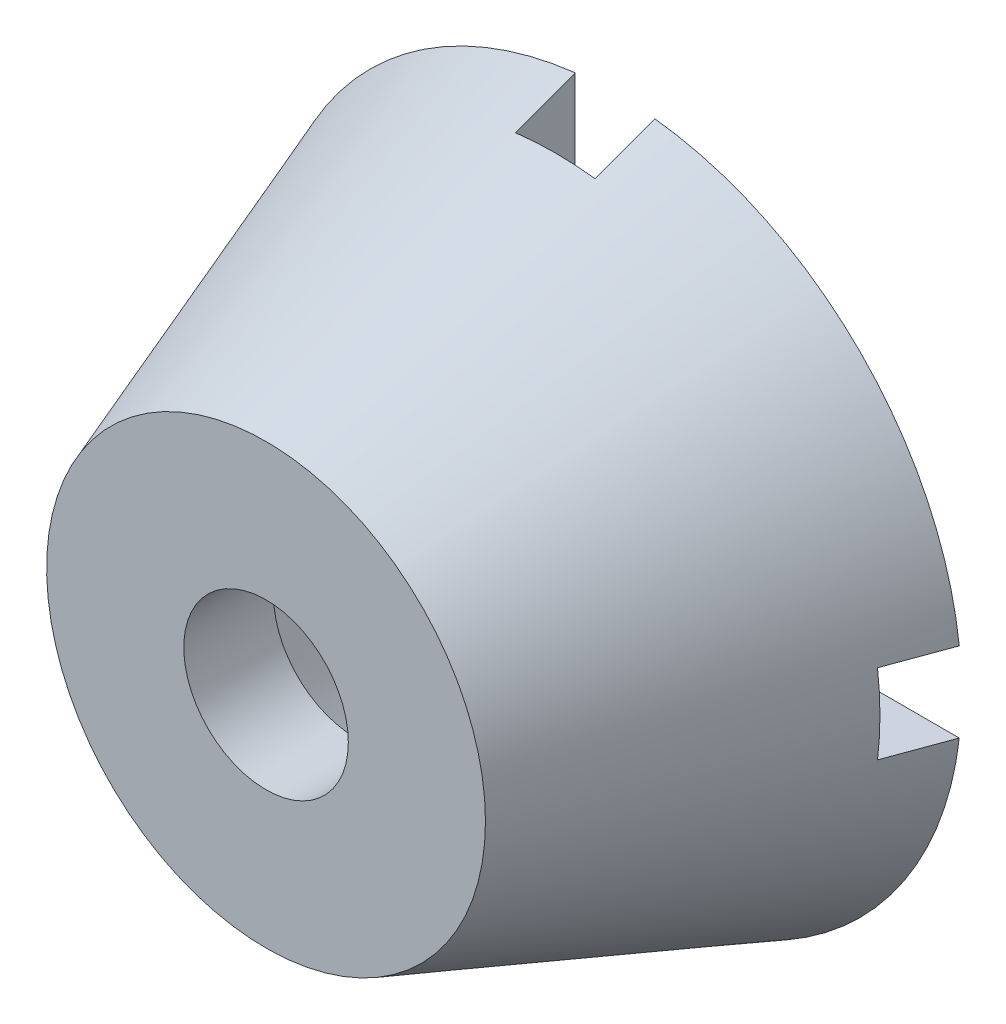
from build123d import *

# Parameters (mm, degrees)
CUT_EXTRUDE_1_REACH      = 37
SKETCH_2_R               = 8.25
SKETCH_3_W               = 8
SKETCH_3_H               = 6
CUT_EXTRUDE_2_DEPTH      = 35.738958199
PATTERN_CIRCULAR_1_COUNT = 4


with BuildPart() as part:
    # 草图1 → 旋转1 (revolve)
    with BuildSketch(Plane(origin=(0, 0, 0), x_dir=(1, 0, 0), z_dir=(0, 1, 0))):
        Polygon((-22, 0), (0, 0), (0, 9), (-15.698132156, 9), (-25.161358247, 35), (-34.738958199, 35), align=None)
    revolve(axis=Axis((0, 0, 0), (0, 0, -1)))

    # 草图2 → 切除-拉伸1 (cut, up to next)
    with BuildSketch(Plane.XY, mode=Mode.PRIVATE) as cut_extrude_1_sk1:
        Circle(SKETCH_2_R)
    cut_extrude_1_tool1 = extrude(cut_extrude_1_sk1.sketch, amount=-CUT_EXTRUDE_1_REACH, mode=Mode.PRIVATE) & part.part
    add(cut_extrude_1_tool1.solids().sort_by_distance((0, 0, 0))[0], mode=Mode.SUBTRACT)

    # 草图3 → 切除-拉伸2 (cut, symmetric)
    with BuildSketch(Plane(origin=(0, 0, 0), x_dir=(1, 0, 0), z_dir=(0, 1, 0))):
        with Locations((0, 32)):
            Rectangle(SKETCH_3_W, SKETCH_3_H)
    cut_extrude_2 = extrude(amount=CUT_EXTRUDE_2_DEPTH, both=True, mode=Mode.SUBTRACT)

    # 阵列(圆周)1: 切除-拉伸2 ×4 about axis
    pattern_circular_1_axis = Axis((0, 0, 0), (0, 0, 1))
    for i in range(1, PATTERN_CIRCULAR_1_COUNT):
        add(cut_extrude_2.rotate(pattern_circular_1_axis, i * 360 / PATTERN_CIRCULAR_1_COUNT), mode=Mode.SUBTRACT)


solid = part.part
